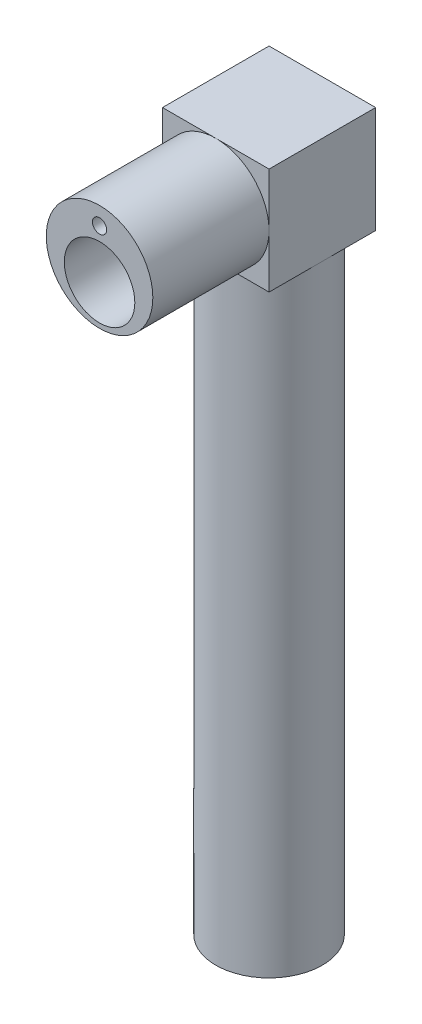
from build123d import *

# Parameters (mm, degrees)
SKETCH1_R           = 28.1
BOSS_EXTRUDE2_DEPTH = 61.3
SKETCH3_R           = 18.6
CUT_EXTRUDE2_DEPTH  = 58.8
SKETCH4_W           = 56.2
SKETCH4_H           = 56.2
BOSS_EXTRUDE3_DEPTH = 56.2
SKETCH5_R           = 16.1
CUT_EXTRUDE4_DEPTH  = 5
SKETCH6_W           = 49.797391422
SKETCH6_H           = 49.779255452
CUT_EXTRUDE5_DEPTH  = 53.7
SKETCH7_R           = 28.1
BOSS_EXTRUDE4_DEPTH = 321.5
CUT_EXTRUDE6_DEPTH  = 10
SKETCH9_R           = 3
CUT_EXTRUDE7_DEPTH  = 1
SKETCH10_R          = 6.025
CUT_EXTRUDE8_DEPTH  = 0.1
SKETCH18_R          = 3.75
CUT_EXTRUDE9_DEPTH  = 100
SKETCH19_R          = 3.75
CUT_EXTRUDE11_DEPTH = 325


with BuildPart() as part:
    # Sketch1 → Boss-Extrude2 (new body)
    with BuildSketch(Plane.XY):
        Circle(SKETCH1_R)
    extrude(amount=BOSS_EXTRUDE2_DEPTH)

    # Sketch3 → Cut-Extrude2 (cut)
    with BuildSketch(Plane.XY.offset(61.3)):
        with Locations((0, -7)):
            Circle(SKETCH3_R)
    extrude(amount=-CUT_EXTRUDE2_DEPTH, mode=Mode.SUBTRACT)

    # Sketch4 → Boss-Extrude3 (add)
    with BuildSketch(Plane(origin=(0, 0, 0), x_dir=(-1, 0, 0), z_dir=(0, 0, -1))):
        Rectangle(SKETCH4_W, SKETCH4_H)
    extrude(amount=BOSS_EXTRUDE3_DEPTH)

    # Sketch5 → Cut-Extrude4 (cut)
    with BuildSketch(Plane.XY.offset(2.5)):
        with Locations((0, -7)):
            Circle(SKETCH5_R)
    extrude(amount=-CUT_EXTRUDE4_DEPTH, mode=Mode.SUBTRACT)

    # Sketch6 → Cut-Extrude5 (cut)
    with BuildSketch(Plane(origin=(0, 0, -56.2), x_dir=(-1, 0, 0), z_dir=(0, 0, -1))):
        Rectangle(SKETCH6_W, SKETCH6_H)
    extrude(amount=-CUT_EXTRUDE5_DEPTH, mode=Mode.SUBTRACT)

    # Sketch7 → Boss-Extrude4 (add)
    with BuildSketch(Plane(origin=(0, -28.1, 0), x_dir=(-1, 0, 0), z_dir=(0, -1, 0))):
        with Locations(Location((0, 28.1, 0), (0, 0, 90))):
            Circle(SKETCH7_R)
    extrude(amount=BOSS_EXTRUDE4_DEPTH)

    # Sketch8 → Cut-Extrude6 (cut)
    with BuildSketch(Plane(origin=(0, -349.6, 0), x_dir=(-1, 0, 0), z_dir=(0, -1, 0))):
        with BuildLine():
            Line((-1.658312395, 25.832078896), (1.658312395, 25.832078896))
            ThreePointArc((1.658312395, 25.832078896), (3, 28.332078896), (1.658312395, 30.832078896))
            Line((1.658312395, 30.832078896), (-1.658312395, 30.832078896))
            ThreePointArc((-1.658312395, 30.832078896), (-3, 28.332078896), (-1.658312395, 25.832078896))
        make_face()
    extrude(amount=-CUT_EXTRUDE6_DEPTH, mode=Mode.SUBTRACT)

    # Sketch9 → Cut-Extrude7 (cut)
    with BuildSketch(Plane(origin=(0, -349.6, 0), x_dir=(-1, 0, 0), z_dir=(0, -1, 0))):
        with Locations(Location((0, 28.332078896, 0), (0, 0, 90))):
            Circle(SKETCH9_R)
    extrude(amount=-CUT_EXTRUDE7_DEPTH, mode=Mode.SUBTRACT)

    # Sketch10 → Cut-Extrude8 (cut)
    with BuildSketch(Plane(origin=(0, -349.6, 0), x_dir=(-1, 0, 0), z_dir=(0, -1, 0))):
        with Locations(Location((0, 28.332078896, 0), (0, 0, 90))):
            Circle(SKETCH10_R)
    extrude(amount=-CUT_EXTRUDE8_DEPTH, mode=Mode.SUBTRACT)

    # Cut-Sweep4: sweep along a path in Sketch15
    with BuildLine(Plane(origin=(0, -349.6, 0), x_dir=(-1, 0, 0), z_dir=(0, -1, 0))) as cut_sweep4_path:
        ThreePointArc((15, 28.332078896), (0, 43.332078896), (-15, 28.332078896))
    # 3DSketch2 → Cut-Sweep4 (sweep, cut)
    with BuildSketch(Plane(origin=(-15, -349.6, -28.332078896), x_dir=(-0.022748965612757834, 0.999741208795331, 0), z_dir=(0, 0, 1))):
        Polygon((0, 0), (0.170617242, 7.498059066), (329.685319661, 0), (329.514702419, -7.498059066), align=None)
    sweep(path=cut_sweep4_path.line, mode=Mode.SUBTRACT)

    # Sketch18 → Cut-Extrude9 (cut)
    with BuildSketch(Plane.XY.offset(61.3)):
        with Locations((0, 18.75)):
            Circle(SKETCH18_R)
    extrude(amount=-CUT_EXTRUDE9_DEPTH, mode=Mode.SUBTRACT)

    # Sketch19 → Cut-Extrude11 (cut)
    with BuildSketch(Plane(origin=(0, -349.6, 0), x_dir=(-1, 0, 0), z_dir=(0, -1, 0))):
        with Locations((-18.75, 28.332078896)):
            Circle(SKETCH19_R)
        with Locations((18.75, 28.332078896)):
            Circle(SKETCH19_R)
    extrude(amount=-CUT_EXTRUDE11_DEPTH, mode=Mode.SUBTRACT)


solid = part.part
